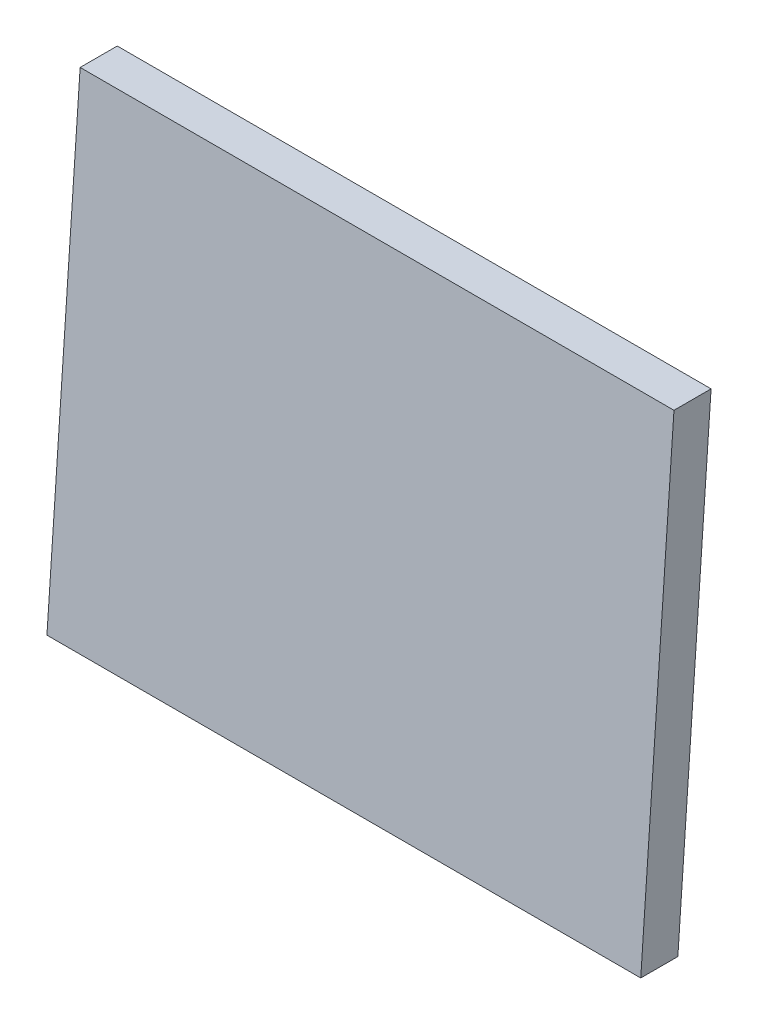
from build123d import *

# Parameters (mm, degrees)
BOSS_EXTRUDE1_DEPTH = 400


with BuildPart() as part:
    # Sketch1 → Boss-Extrude1 (new body)
    with BuildSketch(Plane(origin=(0, 0, 0), x_dir=(0, 0, -1), z_dir=(1, 0, 0))):
        Polygon((-25, 0), (0, 0), (22.376579822, 320), (-2.623420178, 320), align=None)
    extrude(amount=BOSS_EXTRUDE1_DEPTH)


solid = part.part
